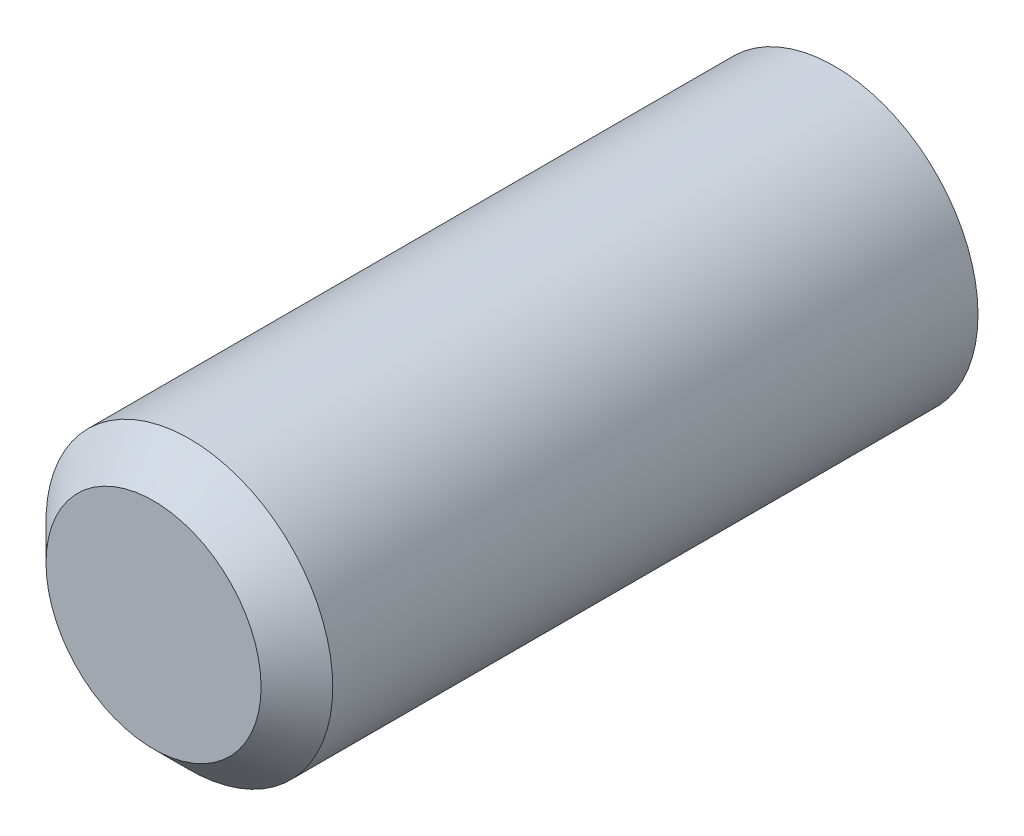
from build123d import *

# Parameters (mm, degrees)
SKETCH1_R           = 10
BOSS_EXTRUDE1_DEPTH = 47.5
CHAMFER1_SIZE       = 2.5


with BuildPart() as part:
    # Sketch1 → Boss-Extrude1 (new body)
    with BuildSketch(Plane.XY):
        Circle(SKETCH1_R)
    extrude(amount=BOSS_EXTRUDE1_DEPTH)

    # Chamfer1
    chamfer1_edges = [part.edges().sort_by_distance(p)[0] for p in [
        (-10, 0, 47.5),
    ]]
    chamfer(chamfer1_edges, length=CHAMFER1_SIZE)


solid = part.part
